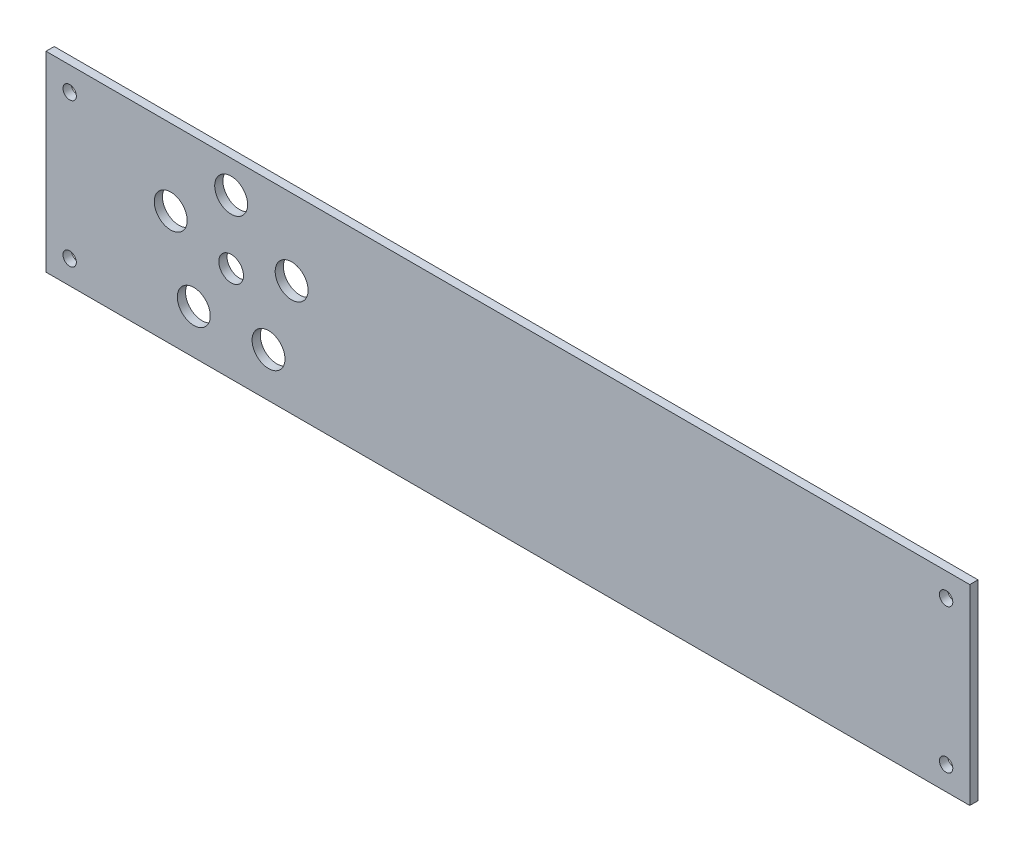
from build123d import *

# Parameters (mm, degrees)
SCHIZZO1_W                   = 449
SCHIZZO1_H                   = 93
SCHIZZO1_R                   = 8
SCHIZZO1_R_2                 = 3.25
SCHIZZO1_R_3                 = 6
ESTRUSIONE_ESTRUSIONE1_DEPTH = 4


with BuildPart() as part:
    # Schizzo1 → Estrusione-Estrusione1 (new body)
    with BuildSketch(Plane.XY):
        with Locations((-224.5, 46.5)):
            Rectangle(SCHIZZO1_W, SCHIZZO1_H)
        with Locations((-388.389262615, 56.049150281)):
            Circle(SCHIZZO1_R, mode=Mode.SUBTRACT)
        with Locations((-437.5, 81.5)):
            Circle(SCHIZZO1_R_2, mode=Mode.SUBTRACT)
        with Locations((-11.5, 81.5)):
            Circle(SCHIZZO1_R_2, mode=Mode.SUBTRACT)
        with Locations((-11.5, 11.5)):
            Circle(SCHIZZO1_R_2, mode=Mode.SUBTRACT)
        with Locations((-437.5, 11.5)):
            Circle(SCHIZZO1_R_2, mode=Mode.SUBTRACT)
        with Locations((-359, 77.401699437)):
            Circle(SCHIZZO1_R, mode=Mode.SUBTRACT)
        with Locations((-329.610737385, 56.049150281)):
            Circle(SCHIZZO1_R, mode=Mode.SUBTRACT)
        with Locations((-340.8364368, 21.5)):
            Circle(SCHIZZO1_R, mode=Mode.SUBTRACT)
        with Locations((-377.1635632, 21.5)):
            Circle(SCHIZZO1_R, mode=Mode.SUBTRACT)
        with Locations((-359, 46.5)):
            Circle(SCHIZZO1_R_3, mode=Mode.SUBTRACT)
    extrude(amount=ESTRUSIONE_ESTRUSIONE1_DEPTH)


solid = part.part
